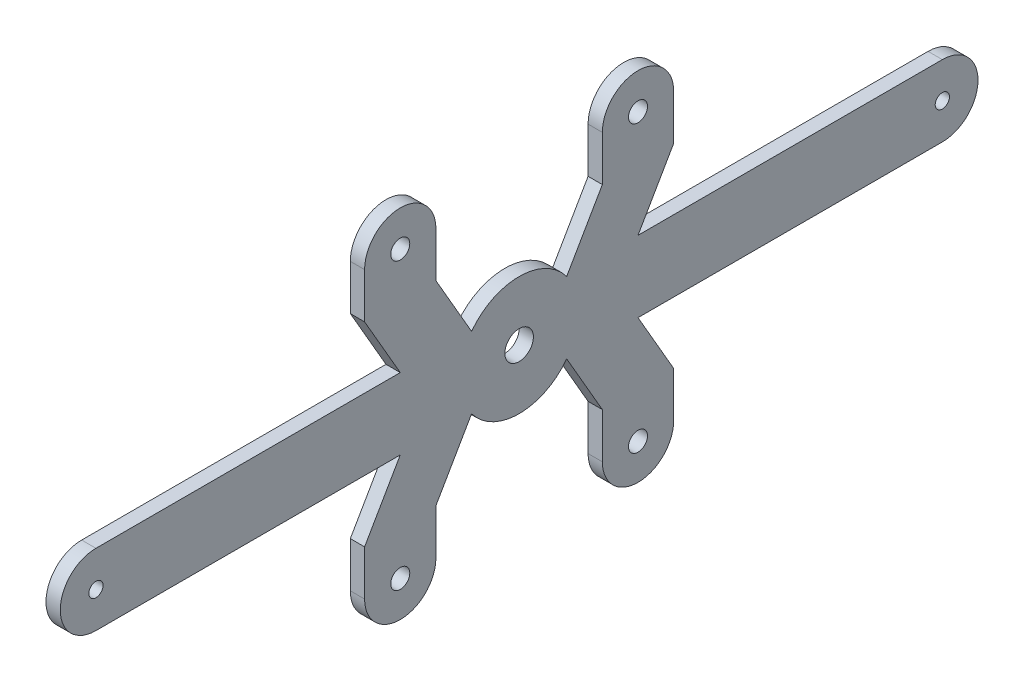
from build123d import *

# Parameters (mm, degrees)
SKETCH1_W               = 210
SKETCH1_H               = 90
BOSS_EXTRUDE1_DEPTH     = 3
SKETCH2_R               = 1.5
CUT_EXTRUDE1_DEPTH      = 4
SKETCH3_R               = 2
CUT_EXTRUDE2_DEPTH      = 4
CUT_EXTRUDE3_DEPTH      = 4
MIRROR3_COPY_1_SKETCH_R = 2
MIRROR3_COPY_1_DEPTH    = 4
MIRROR3_COPY_2_DEPTH    = 4
SKETCH5_R               = 3
CUT_EXTRUDE4_DEPTH      = 4


with BuildPart() as part:
    # Sketch1 → Boss-Extrude1 (new body)
    with BuildSketch(Plane(origin=(0, 0, 0), x_dir=(0, 0, -1), z_dir=(1, 0, 0))):
        Rectangle(SKETCH1_W, SKETCH1_H)
    extrude(amount=BOSS_EXTRUDE1_DEPTH)

    # Sketch2 → Cut-Extrude1 (cut, through all)
    with BuildSketch(Plane(origin=(3, 0, 0), x_dir=(0, 0, -1), z_dir=(1, 0, 0))):
        with Locations((-89, 0)):
            Circle(SKETCH2_R)
    cut_extrude1 = extrude(amount=-CUT_EXTRUDE1_DEPTH, mode=Mode.SUBTRACT)

    # Sketch3 → Cut-Extrude2 (cut, through all)
    with BuildSketch(Plane(origin=(3, 0, 0), x_dir=(0, 0, -1), z_dir=(1, 0, 0))):
        with Locations((-25, 30)):
            Circle(SKETCH3_R)
    cut_extrude2 = extrude(amount=-CUT_EXTRUDE2_DEPTH, mode=Mode.SUBTRACT)

    # Sketch4 → Cut-Extrude3 (cut, through all)
    with BuildSketch(Plane(origin=(3, 0, 0), x_dir=(0, 0, -1), z_dir=(1, 0, 0))):
        with BuildLine():
            Line((-105, 0), (-105, 45))
            Line((-105, 45), (0, 45))
            Line((0, 45), (0, 40))
            Line((0, 40), (0, 12.5))
            ThreePointArc((0, 12.5), (-5.590169944, 11.180339887), (-10, 7.5))
            Line((-10, 7.5), (-17.5, 20.490381057))
            Line((-17.5, 20.490381057), (-17.5, 30))
            ThreePointArc((-17.5, 30), (-25, 37.5), (-32.5, 30))
            Line((-32.5, 30), (-32.5, 20.490381057))
            Line((-32.5, 20.490381057), (-25, 7.5))
            Line((-25, 7.5), (-89, 7.5))
            ThreePointArc((-89, 7.5), (-94.303300859, 5.303300859), (-96.5, 0))
            Line((-96.5, 0), (-105, 0))
        make_face()
    cut_extrude3 = extrude(amount=-CUT_EXTRUDE3_DEPTH, mode=Mode.SUBTRACT)

    # Mirror2: Cut-Extrude2, Cut-Extrude3 across plane
    add(cut_extrude2.mirror(Plane.ZX), mode=Mode.SUBTRACT)
    add(cut_extrude3.mirror(Plane.ZX), mode=Mode.SUBTRACT)

    # Mirror3: Cut-Extrude3, Cut-Extrude1, Cut-Extrude2 across plane
    add(cut_extrude3.mirror(Plane.XY), mode=Mode.SUBTRACT)
    add(cut_extrude1.mirror(Plane.XY), mode=Mode.SUBTRACT)
    add(cut_extrude2.mirror(Plane.XY), mode=Mode.SUBTRACT)

    # Mirror3 copy 1 sketch → Mirror3 copy 1 (cut, through all)
    with BuildSketch(Plane(origin=(3, 0, 0), x_dir=(0, 0, 1), z_dir=(1, 0, 0))):
        with Locations((-25, 30)):
            Circle(MIRROR3_COPY_1_SKETCH_R)
    extrude(amount=-MIRROR3_COPY_1_DEPTH, mode=Mode.SUBTRACT)

    # Mirror3 copy 2 sketch → Mirror3 copy 2 (cut, through all)
    with BuildSketch(Plane(origin=(3, 0, 0), x_dir=(0, 0, 1), z_dir=(1, 0, 0))):
        with BuildLine():
            Line((-105, 0), (-105, 45))
            Line((-105, 45), (0, 45))
            Line((0, 45), (0, 40))
            Line((0, 40), (0, 12.5))
            ThreePointArc((0, 12.5), (-5.590169944, 11.180339887), (-10, 7.5))
            Line((-10, 7.5), (-17.5, 20.490381057))
            Line((-17.5, 20.490381057), (-17.5, 30))
            ThreePointArc((-17.5, 30), (-25, 37.5), (-32.5, 30))
            Line((-32.5, 30), (-32.5, 20.490381057))
            Line((-32.5, 20.490381057), (-25, 7.5))
            Line((-25, 7.5), (-89, 7.5))
            ThreePointArc((-89, 7.5), (-94.303300859, 5.303300859), (-96.5, 0))
            Line((-96.5, 0), (-105, 0))
        make_face()
    extrude(amount=-MIRROR3_COPY_2_DEPTH, mode=Mode.SUBTRACT)

    # Sketch5 → Cut-Extrude4 (cut, through all)
    with BuildSketch(Plane(origin=(3, 0, 0), x_dir=(0, 0, -1), z_dir=(1, 0, 0))):
        Circle(SKETCH5_R)
    extrude(amount=-CUT_EXTRUDE4_DEPTH, mode=Mode.SUBTRACT)


solid = part.part
